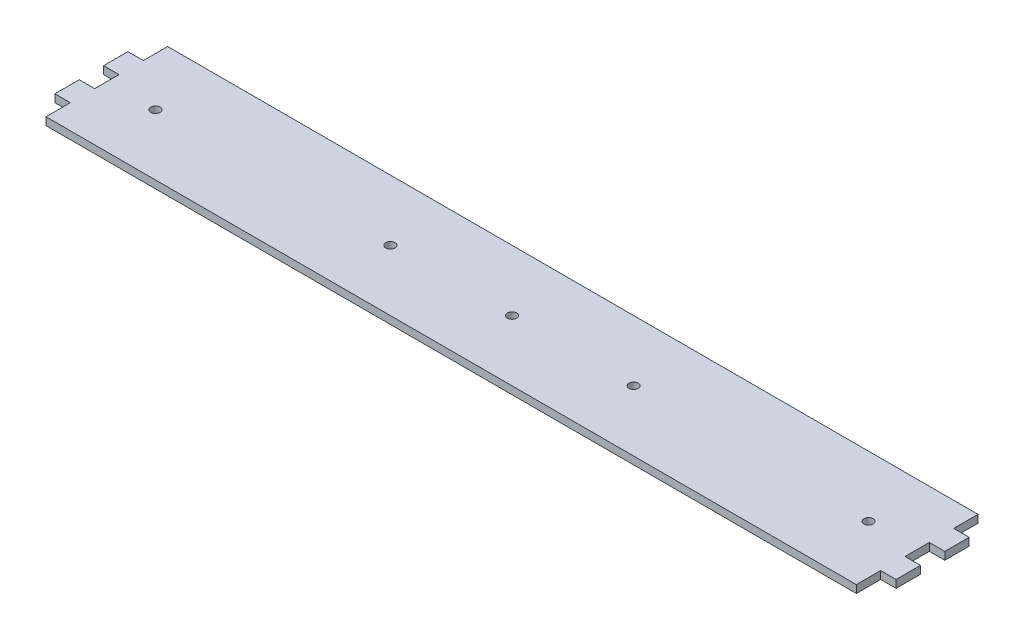
from build123d import *

# Parameters (mm, degrees)
SKETCH1_W           = 333
SKETCH1_H           = 50
SKETCH1_R           = 1.9
SKETCH1_W_2         = 6.35
SKETCH1_H_2         = 10
BOSS_EXTRUDE1_DEPTH = 3.175


with BuildPart() as part:
    # Sketch1 → Boss-Extrude1 (new body)
    with BuildSketch(Plane(origin=(0, 0, 0), x_dir=(1, 0, 0), z_dir=(0, 1, 0))):
        Rectangle(SKETCH1_W, SKETCH1_H)
        Circle(SKETCH1_R, mode=Mode.SUBTRACT)
        with Locations((50, 0)):
            Circle(SKETCH1_R, mode=Mode.SUBTRACT)
        with Locations((-50, 0)):
            Circle(SKETCH1_R, mode=Mode.SUBTRACT)
        with Locations((146.5, 0)):
            Circle(SKETCH1_R, mode=Mode.SUBTRACT)
        with Locations((-146.5, 0)):
            Circle(SKETCH1_R, mode=Mode.SUBTRACT)
        with Locations((-169.675, 10)):
            Rectangle(SKETCH1_W_2, SKETCH1_H_2)
        with Locations((169.675, 10)):
            Rectangle(SKETCH1_W_2, SKETCH1_H_2)
        with Locations((169.675, -10)):
            Rectangle(SKETCH1_W_2, SKETCH1_H_2)
        with Locations((-169.675, -10)):
            Rectangle(SKETCH1_W_2, SKETCH1_H_2)
    extrude(amount=BOSS_EXTRUDE1_DEPTH)


solid = part.part
